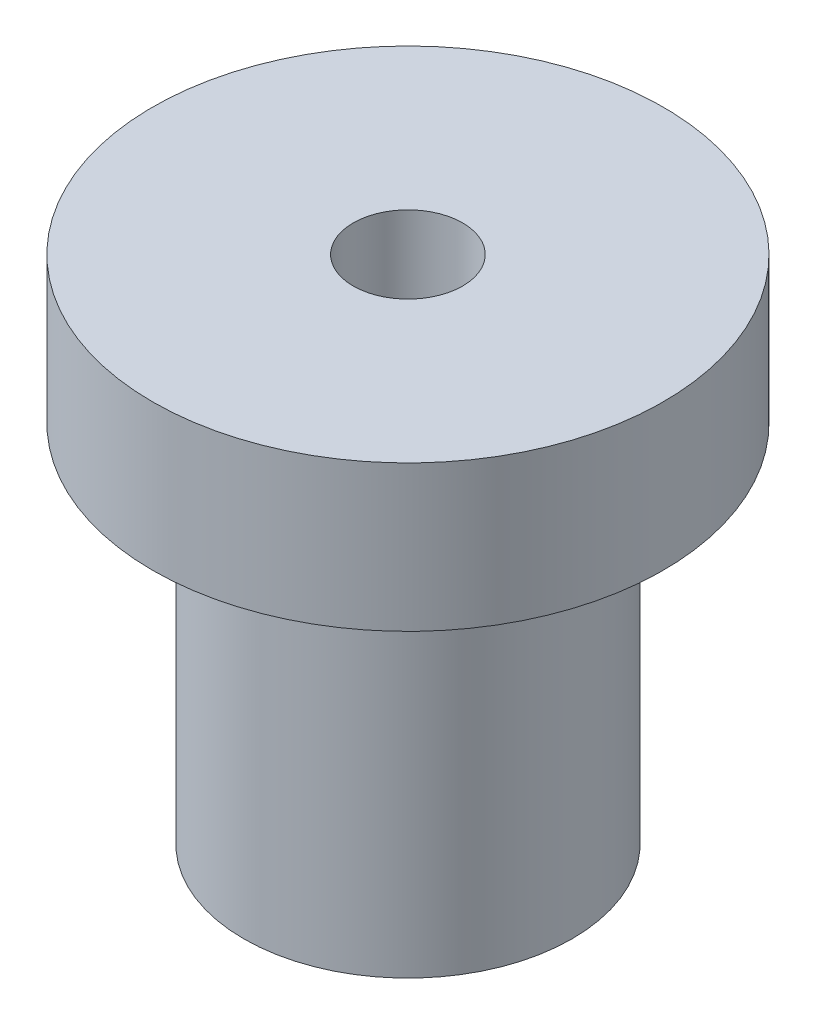
from build123d import *

# Parameters (mm, degrees)
SKETCH1_R           = 9
BOSS_EXTRUDE1_DEPTH = 20
SKETCH2_R           = 3
CUT_EXTRUDE1_DEPTH  = 52
SKETCH3_R           = 14
BOSS_EXTRUDE2_DEPTH = 8
SKETCH4_R           = 3
CUT_EXTRUDE2_DEPTH  = 12


with BuildPart() as part:
    # Sketch1 → Boss-Extrude1 (new body)
    with BuildSketch(Plane(origin=(0, 0, 0), x_dir=(1, 0, 0), z_dir=(0, 1, 0))):
        Circle(SKETCH1_R)
    extrude(amount=BOSS_EXTRUDE1_DEPTH)

    # Sketch2 → Cut-Extrude1 (cut)
    with BuildSketch(Plane.XZ):
        Circle(SKETCH2_R)
    extrude(amount=-CUT_EXTRUDE1_DEPTH, mode=Mode.SUBTRACT)

    # Sketch3 → Boss-Extrude2 (add)
    with BuildSketch(Plane(origin=(0, 20, 0), x_dir=(1, 0, 0), z_dir=(0, 1, 0))):
        Circle(SKETCH3_R)
    extrude(amount=BOSS_EXTRUDE2_DEPTH)

    # Sketch4 → Cut-Extrude2 (cut)
    with BuildSketch(Plane(origin=(0, 28, 0), x_dir=(1, 0, 0), z_dir=(0, 1, 0))):
        Circle(SKETCH4_R)
    extrude(amount=-CUT_EXTRUDE2_DEPTH, mode=Mode.SUBTRACT)


solid = part.part
